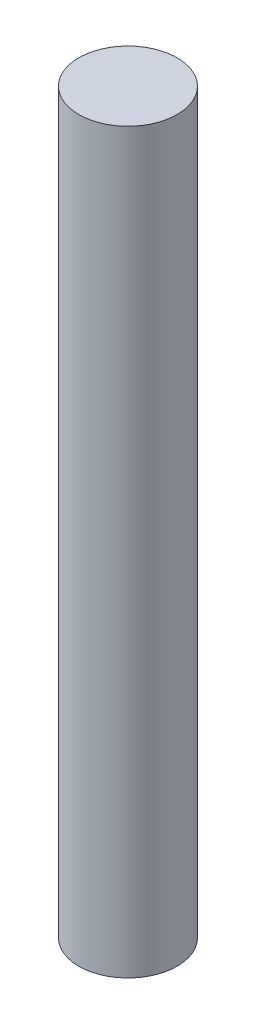
from build123d import *

# Parameters (mm, degrees)
SKETCH1_R           = 4
BOSS_EXTRUDE1_DEPTH = 30


with BuildPart() as part:
    # Sketch1 → Boss-Extrude1 (new body, symmetric)
    with BuildSketch(Plane(origin=(0, 0, 0), x_dir=(1, 0, 0), z_dir=(0, 1, 0))):
        Circle(SKETCH1_R)
    extrude(amount=BOSS_EXTRUDE1_DEPTH, both=True)


solid = part.part
